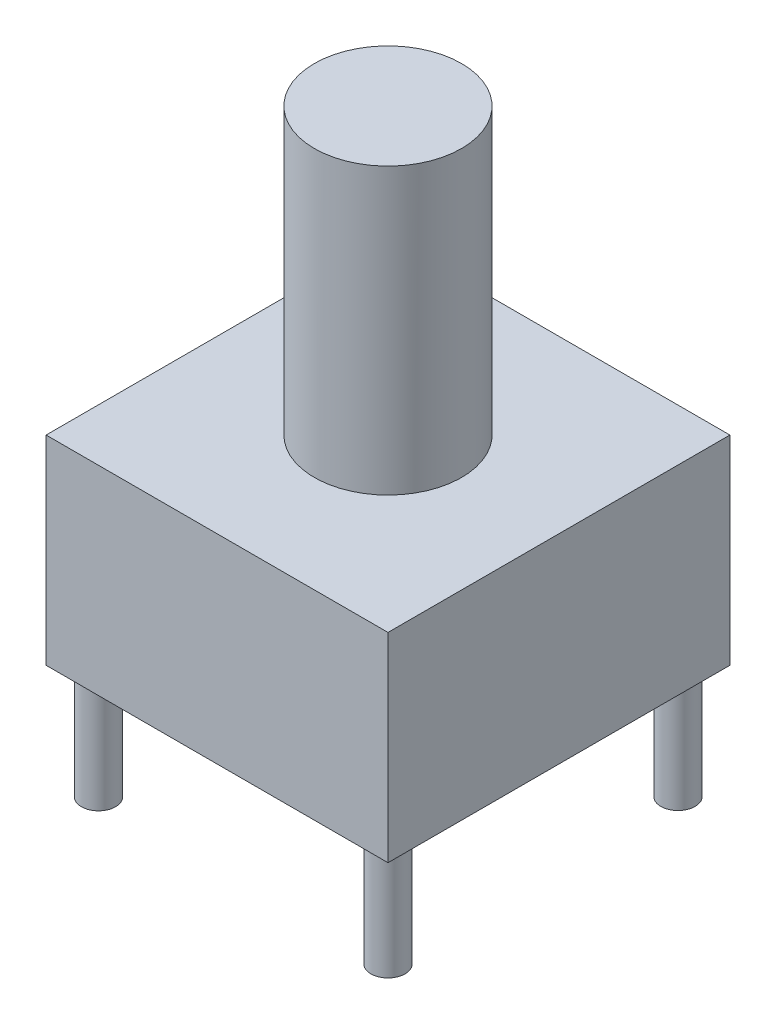
from build123d import *

# Parameters (mm, degrees)
SKETCH1_W           = 6
SKETCH1_H           = 6
BOSS_EXTRUDE1_DEPTH = 3.5
SKETCH2_R           = 1.292115179
BOSS_EXTRUDE2_DEPTH = 5
SKETCH3_R           = 0.3
BOSS_EXTRUDE3_DEPTH = 2


with BuildPart() as part:
    # Sketch1 → Boss-Extrude1 (new body)
    with BuildSketch(Plane(origin=(0, 0, 0), x_dir=(1, 0, 0), z_dir=(0, 1, 0))):
        with Locations((3, 3)):
            Rectangle(SKETCH1_W, SKETCH1_H)
    extrude(amount=BOSS_EXTRUDE1_DEPTH)

    # Sketch2 → Boss-Extrude2 (add)
    with BuildSketch(Plane(origin=(0, 3.5, 0), x_dir=(1, 0, 0), z_dir=(0, 1, 0))):
        with Locations((2.999291, 3)):
            Circle(SKETCH2_R)
    extrude(amount=BOSS_EXTRUDE2_DEPTH)

    # Sketch3 → Boss-Extrude3 (add)
    with BuildSketch(Plane(origin=(0, 0, 0), x_dir=(-1, 0, 0), z_dir=(0, -1, 0))):
        with Locations((-0.46, 0.46)):
            Circle(SKETCH3_R)
        with Locations((-5.54, 0.46)):
            Circle(SKETCH3_R)
        with Locations((-0.46, 5.54)):
            Circle(SKETCH3_R)
        with Locations((-5.54, 5.548881257)):
            Circle(SKETCH3_R)
    extrude(amount=BOSS_EXTRUDE3_DEPTH)


solid = part.part
